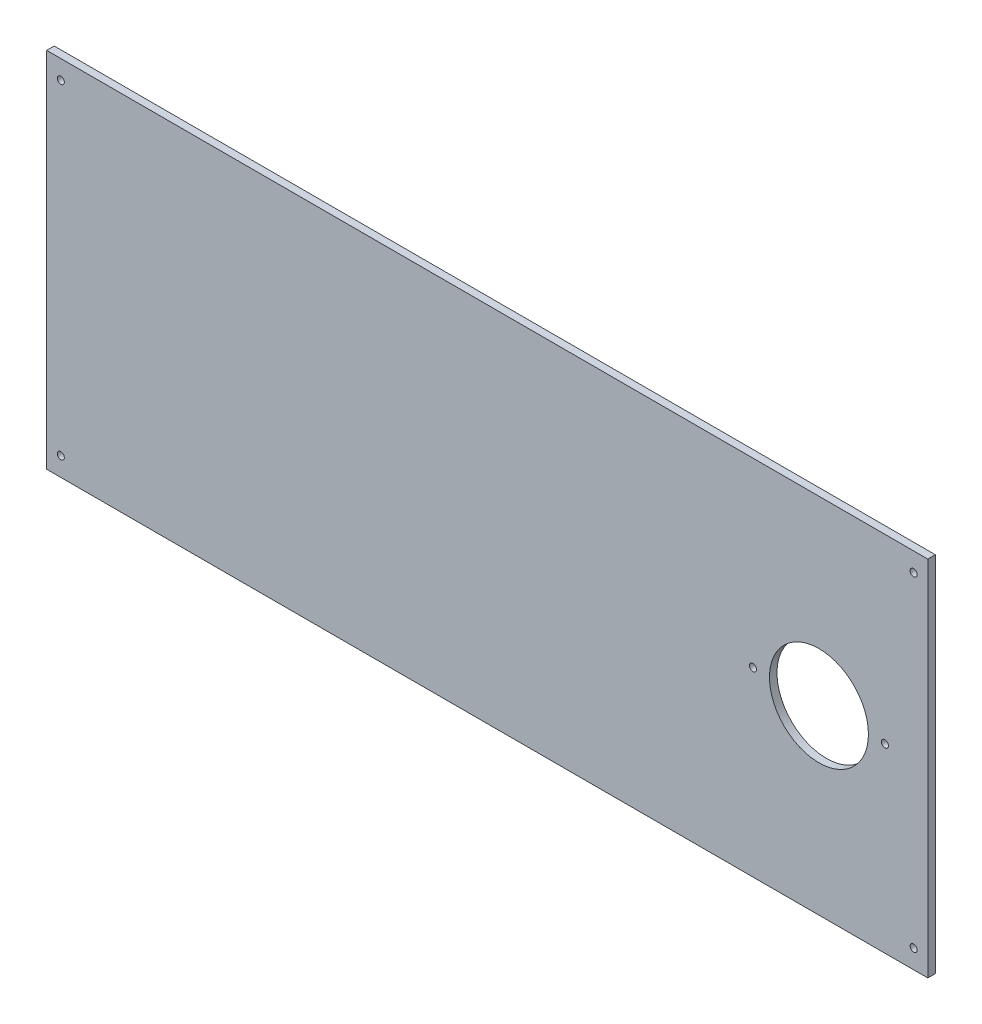
from build123d import *

# Parameters (mm, degrees)
KEEPOUTLAYER_W      = 186.9999816
KEEPOUTLAYER_H      = 76.9999984
EXTRUDE_1_DEPTH     = 1.6
VIAHOLELAYER_R      = 0.7499985
VIAHOLELAYER_R_2    = 10.5
CUT_EXTRUDE_1_DEPTH = 2.6


with BuildPart() as part:
    # KeepOutLayer → Бобышка-Вытянуть1 (new body)
    with BuildSketch(Plane.XY):
        with Locations((93.56941662, -38.56797722)):
            Rectangle(KEEPOUTLAYER_W, KEEPOUTLAYER_H)
    extrude(amount=-EXTRUDE_1_DEPTH)

    # ViaHoleLayer → Вырез-Вытянуть1 (cut, through all)
    with BuildSketch(Plane.XY):
        with Locations((3.0693995, -73.06799966)):
            Circle(VIAHOLELAYER_R)
        with Locations((3.0693995, -4.0680005)):
            Circle(VIAHOLELAYER_R)
        with Locations((184.06940072, -73.06799966)):
            Circle(VIAHOLELAYER_R)
        with Locations((184.06940072, -4.0680005)):
            Circle(VIAHOLELAYER_R)
        with Locations((149.96940542, -38.56797722)):
            Circle(VIAHOLELAYER_R)
        with Locations((177.96940022, -38.56797722)):
            Circle(VIAHOLELAYER_R)
        with Locations((163.96937742, -38.56797722)):
            Circle(VIAHOLELAYER_R_2)
    extrude(amount=-CUT_EXTRUDE_1_DEPTH, mode=Mode.SUBTRACT)


solid = part.part
